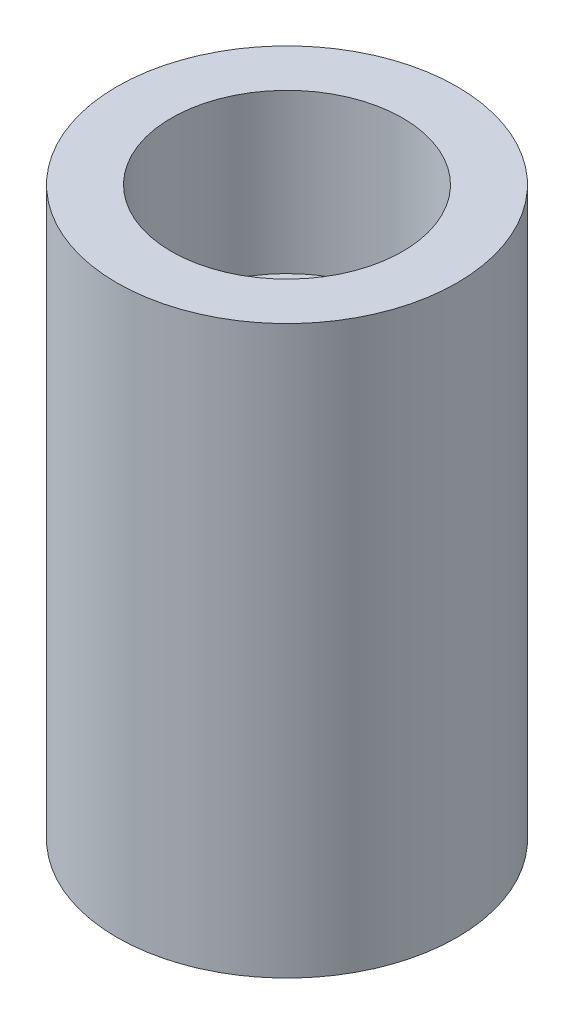
from build123d import *

# Parameters (mm, degrees)
SKETCH1_R           = 7.5
BOSS_EXTRUDE1_DEPTH = 25
SKETCH2_R           = 5.1
CUT_EXTRUDE1_DEPTH  = 7
SKETCH3_R           = 5.1
CUT_EXTRUDE2_DEPTH  = 7
SKETCH4_R           = 4
CUT_EXTRUDE3_DEPTH  = 19


with BuildPart() as part:
    # Sketch1 → Boss-Extrude1 (new body)
    with BuildSketch(Plane(origin=(0, 0, 0), x_dir=(1, 0, 0), z_dir=(0, 1, 0))):
        Circle(SKETCH1_R)
    extrude(amount=BOSS_EXTRUDE1_DEPTH)

    # Sketch2 → Cut-Extrude1 (cut)
    with BuildSketch(Plane.XZ):
        Circle(SKETCH2_R)
    extrude(amount=-CUT_EXTRUDE1_DEPTH, mode=Mode.SUBTRACT)

    # Sketch3 → Cut-Extrude2 (cut)
    with BuildSketch(Plane(origin=(0, 25, 0), x_dir=(1, 0, 0), z_dir=(0, 1, 0))):
        Circle(SKETCH3_R)
    extrude(amount=-CUT_EXTRUDE2_DEPTH, mode=Mode.SUBTRACT)

    # Sketch4 → Cut-Extrude3 (cut, through all)
    with BuildSketch(Plane(origin=(0, 18, 0), x_dir=(1, 0, 0), z_dir=(0, 1, 0))):
        Circle(SKETCH4_R)
    extrude(amount=-CUT_EXTRUDE3_DEPTH, mode=Mode.SUBTRACT)


solid = part.part
